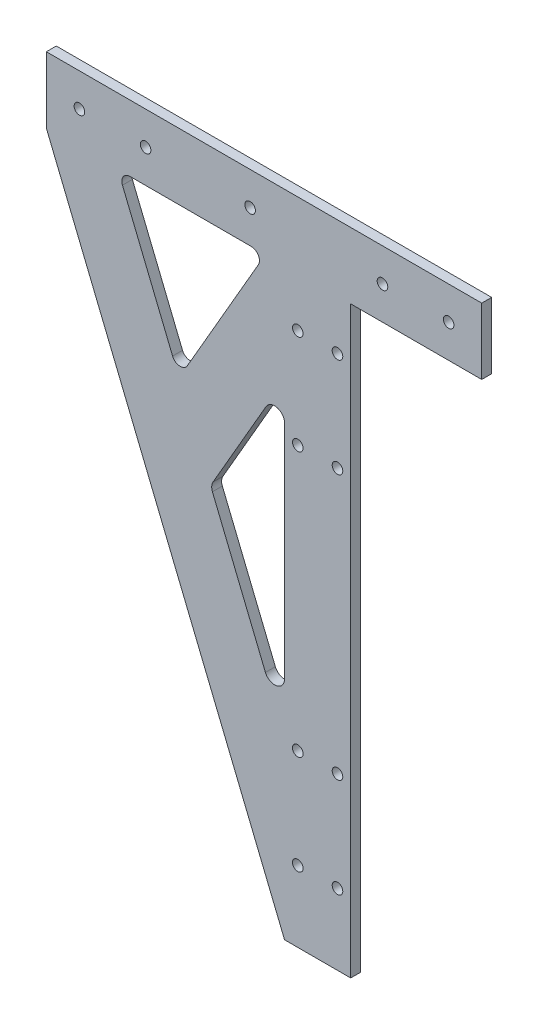
from build123d import *

# Parameters (mm, degrees)
SKETCH1_R      = 1.6
EXTRUDE1_DEPTH = 3


with BuildPart() as part:
    # Sketch1 → Extrude1 (new body)
    with BuildSketch(Plane.XY):
        Polygon((-234.458183995, 0), (-162.458183995, -176.470588235), (-142.458183995, -176.470588235), (-142.458183995, 0), (-102.858183995, 0), (-102.858183995, 20), (-102.863553327, 20), (-234.458183995, 20), align=None)
        with Locations((-112.858183995, 10)):
            Circle(SKETCH1_R, mode=Mode.SUBTRACT)
        with Locations((-132.858183995, 10)):
            Circle(SKETCH1_R, mode=Mode.SUBTRACT)
        with Locations((-172.858183995, 10)):
            Circle(SKETCH1_R, mode=Mode.SUBTRACT)
        with Locations((-146.458183995, -45)):
            Circle(SKETCH1_R, mode=Mode.SUBTRACT)
        with Locations((-158.458183995, -45)):
            Circle(SKETCH1_R, mode=Mode.SUBTRACT)
        with Locations((-146.458183995, -15)):
            Circle(SKETCH1_R, mode=Mode.SUBTRACT)
        with Locations((-158.458183995, -15)):
            Circle(SKETCH1_R, mode=Mode.SUBTRACT)
        with Locations((-224.458183995, 10)):
            Circle(SKETCH1_R, mode=Mode.SUBTRACT)
        with Locations((-204.458183995, 10)):
            Circle(SKETCH1_R, mode=Mode.SUBTRACT)
        with Locations((-158.458183995, -125)):
            Circle(SKETCH1_R, mode=Mode.SUBTRACT)
        with Locations((-146.458183995, -125)):
            Circle(SKETCH1_R, mode=Mode.SUBTRACT)
        with Locations((-158.458183995, -155)):
            Circle(SKETCH1_R, mode=Mode.SUBTRACT)
        with Locations((-146.458183995, -155)):
            Circle(SKETCH1_R, mode=Mode.SUBTRACT)
        with BuildLine():
            Line((-209.152667208, 0), (-172.544179417, 0))
            ThreePointArc((-172.544179417, 0), (-170.387933052, -1.244909419), (-170.387933052, -3.734728258))
            Line((-170.387933052, -3.734728258), (-191.838092393, -40.887494067))
            ThreePointArc((-191.838092393, -40.887494067), (-194.163782936, -42.126631048), (-196.299663326, -40.583157071))
            Line((-196.299663326, -40.583157071), (-211.457991776, -3.430391262))
            ThreePointArc((-211.457991776, -3.430391262), (-211.219192406, -1.101052676), (-209.152667208, 0))
        make_face(mode=Mode.SUBTRACT)
        with BuildLine():
            Line((-162.458183995, -41.196152423), (-162.458183995, -108.233623843))
            ThreePointArc((-162.458183995, -108.233623843), (-164.880734742, -111.177524717), (-168.235885568, -109.366926085))
            Line((-168.235885568, -109.366926085), (-184.261936587, -70.087389274))
            ThreePointArc((-184.261936587, -70.087389274), (-184.477279763, -68.749922566), (-184.082311226, -67.454087032))
            Line((-184.082311226, -67.454087032), (-168.056260207, -39.696152423))
            ThreePointArc((-168.056260207, -39.696152423), (-164.68172686, -38.298374944), (-162.458183995, -41.196152423))
        make_face(mode=Mode.SUBTRACT)
    extrude(amount=EXTRUDE1_DEPTH)


solid = part.part
